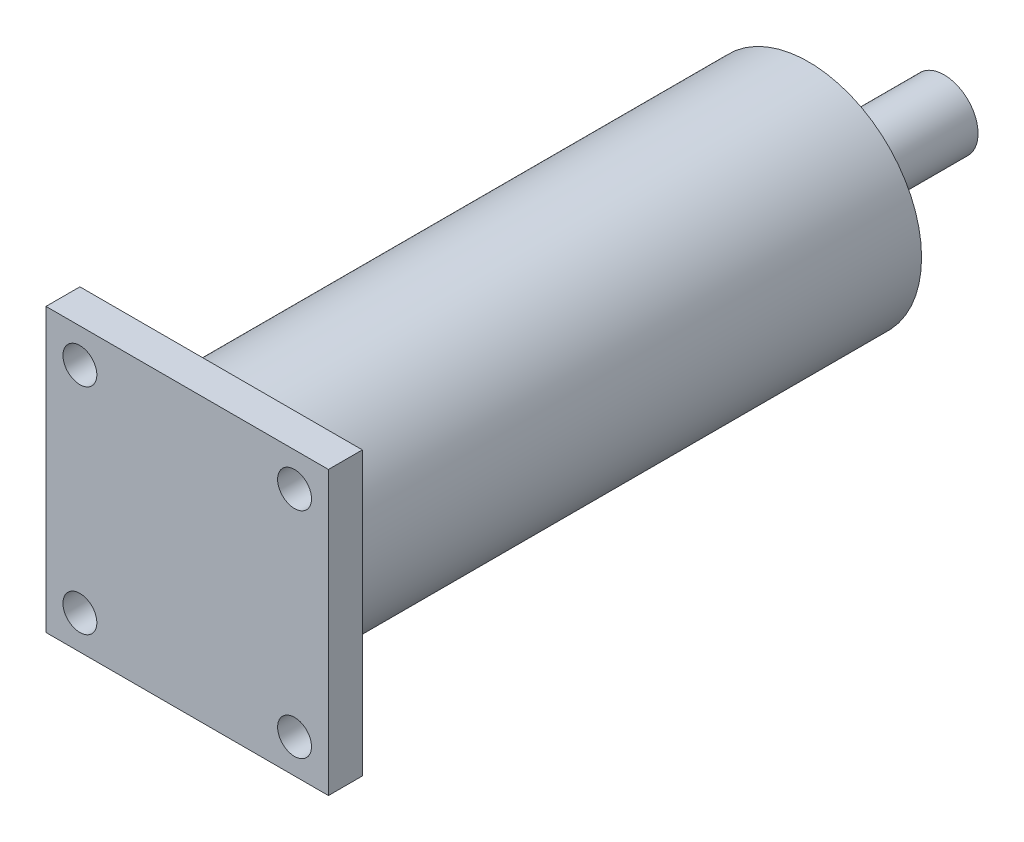
from build123d import *

# Parameters (mm, degrees)
SKETCH_2_W          = 25
SKETCH_2_H          = 25
EXTRUDE_1_DEPTH     = 3
SKETCH_3_R          = 1.5
CUT_EXTRUDE_2_DEPTH = 4
EXTRUDE_START       = -3
SKETCH_4_R          = 10
EXTRUDE_2_DEPTH     = 52
SKETCH_5_R          = 3
EXTRUDE_3_DEPTH     = 12


with BuildPart() as part:
    # 草图2 → 凸台-拉伸1 (new body)
    with BuildSketch(Plane.XY):
        with Locations((12.5, -12.5)):
            Rectangle(SKETCH_2_W, SKETCH_2_H)
    extrude(amount=EXTRUDE_1_DEPTH)

    # 草图3 → 切除-拉伸2 (cut, through all)
    with BuildSketch(Plane(origin=(0, 0, 0), x_dir=(-1, 0, 0), z_dir=(0, 0, -1))):
        with Locations((-22, -3)):
            Circle(SKETCH_3_R)
        with Locations((-3, -3)):
            Circle(SKETCH_3_R)
        with Locations((-3, -22)):
            Circle(SKETCH_3_R)
        with Locations((-22, -22)):
            Circle(SKETCH_3_R)
    extrude(amount=-CUT_EXTRUDE_2_DEPTH, mode=Mode.SUBTRACT)

    # 草图4 → 凸台-拉伸2 (add)
    with BuildSketch(Plane.XY.offset(3).offset(EXTRUDE_START)):
        with Locations((12.5, -12.5)):
            Circle(SKETCH_4_R)
    extrude(amount=-EXTRUDE_2_DEPTH)

    # 草图5 → 凸台-拉伸3 (add)
    with BuildSketch(Plane(origin=(0, 0, -52), x_dir=(-1, 0, 0), z_dir=(0, 0, -1))):
        with Locations((-12.5, -12.5)):
            Circle(SKETCH_5_R)
    extrude(amount=EXTRUDE_3_DEPTH)


solid = part.part
